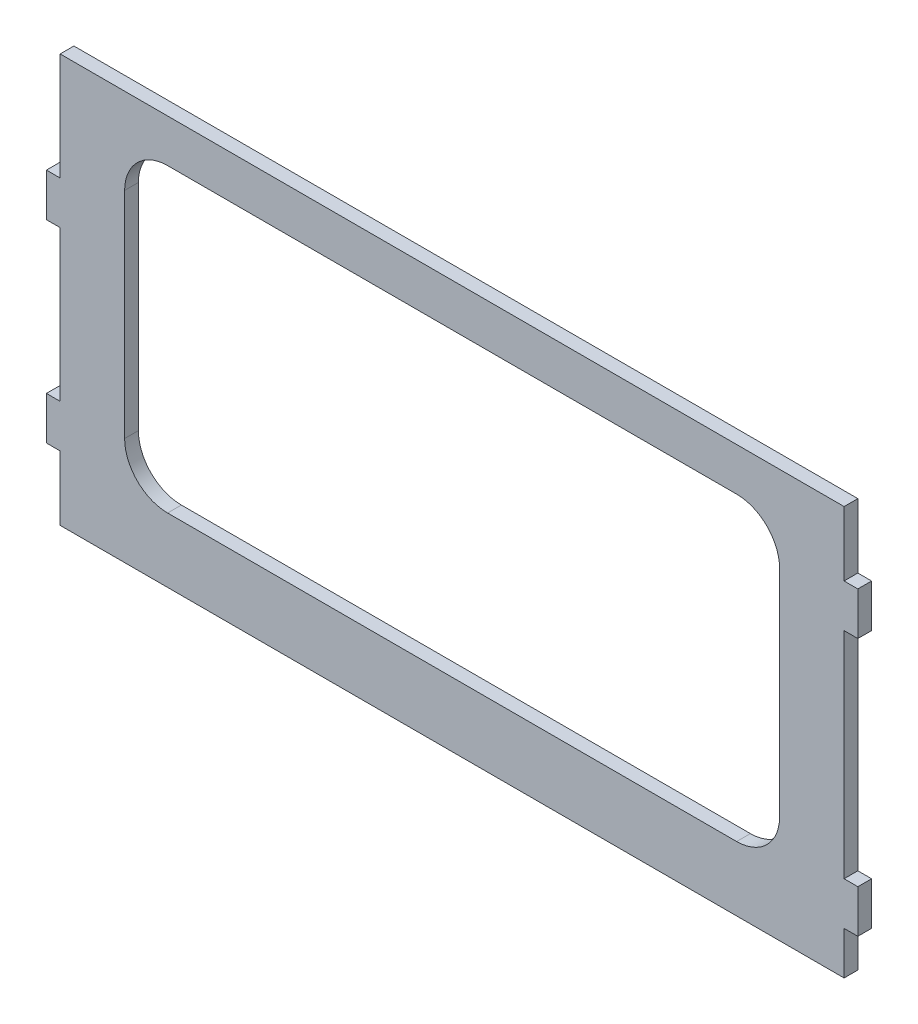
from build123d import *

# Parameters (mm, degrees)
BOSS_EXTRUDE1_DEPTH = 4.064
CUT_EXTRUDE1_DEPTH  = 5.064


with BuildPart() as part:
    # Sketch1 → Boss-Extrude1 (new body)
    with BuildSketch(Plane.XY):
        Polygon((125.750548905, 0), (-105.897451095, 0), (-105.897451095, -31.75), (-109.961451095, -31.75), (-109.961451095, -44.45), (-105.897451095, -44.45), (-105.897451095, -88.9), (-109.961451095, -88.9), (-109.961451095, -101.6), (-105.897451095, -101.6), (-105.897451095, -120.65), (125.750548905, -120.65), (125.750548905, -107.95), (129.814548905, -107.95), (129.814548905, -95.25), (125.750548905, -95.25), (125.750548905, -31.75), (129.814548905, -31.75), (129.814548905, -19.05), (125.750548905, -19.05), align=None)
    extrude(amount=BOSS_EXTRUDE1_DEPTH)

    # Sketch2 → Cut-Extrude1 (cut, through all)
    with BuildSketch(Plane.XY.offset(4.064)):
        with BuildLine():
            Line((-74.147451095, -12.7), (94.000548905, -12.7))
            ThreePointArc((94.000548905, -12.7), (102.980805026, -16.419743879), (106.700548905, -25.4))
            Line((106.700548905, -25.4), (106.700548905, -88.9))
            ThreePointArc((106.700548905, -88.9), (102.980805026, -97.880256121), (94.000548905, -101.6))
            Line((94.000548905, -101.6), (-74.147451095, -101.6))
            ThreePointArc((-74.147451095, -101.6), (-83.127707216, -97.880256121), (-86.847451095, -88.9))
            Line((-86.847451095, -88.9), (-86.847451095, -25.4))
            ThreePointArc((-86.847451095, -25.4), (-83.127707216, -16.419743879), (-74.147451095, -12.7))
        make_face()
    extrude(amount=-CUT_EXTRUDE1_DEPTH, mode=Mode.SUBTRACT)


solid = part.part
